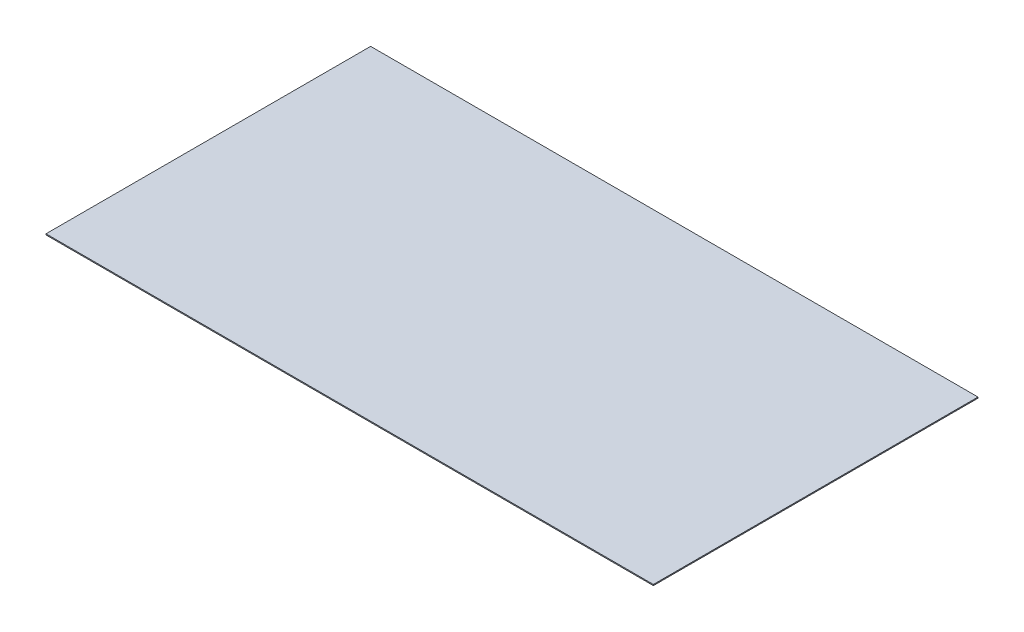
from build123d import *

# Parameters (mm, degrees)
SKETCH2_W           = 580
SKETCH2_H           = 310
BOSS_EXTRUDE3_DEPTH = 1


with BuildPart() as part:
    # Sketch2 → Boss-Extrude3 (new body)
    with BuildSketch(Plane(origin=(0, 0, 0), x_dir=(1, 0, 0), z_dir=(0, 1, 0))):
        Rectangle(SKETCH2_W, SKETCH2_H)
    extrude(amount=BOSS_EXTRUDE3_DEPTH)


solid = part.part
